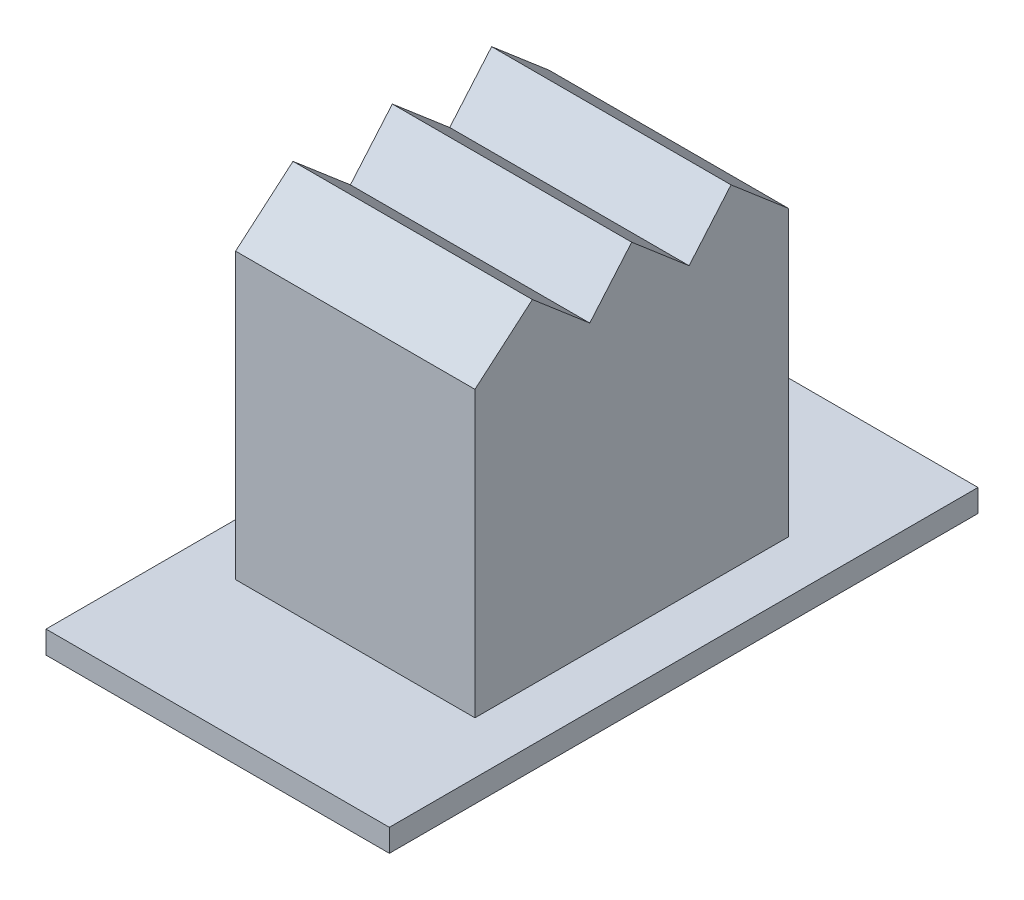
from build123d import *

# Parameters (mm, degrees)
SKICA1_W                 = 7
SKICA1_H                 = 12
SKICA1_W_2               = 2.46
SKICA1_H_2               = 2.37
P_IDAT_VYSUNUT_M1_DEPTH  = 0.46
SKICA2_W                 = 4.88
SKICA2_H                 = 6.39
SKICA2_W_2               = 2.46
SKICA2_H_2               = 2.37
P_IDAT_VYSUNUT_M2_DEPTH  = 4
SKICA3_W                 = 4.88
SKICA3_H                 = 6.39
P_IDAT_VYSUNUT_M3_DEPTH  = 2.8
ODEBRAT_VYSUNUT_M1_DEPTH = 10


with BuildPart() as part:
    # Skica1 → Přidat vysunutím1 (new body)
    with BuildSketch(Plane(origin=(0, 0, 0), x_dir=(1, 0, 0), z_dir=(0, 1, 0))):
        with Locations((3.5, 6)):
            Rectangle(SKICA1_W, SKICA1_H)
        with Locations((3.5, 6)):
            Rectangle(SKICA1_W_2, SKICA1_H_2, mode=Mode.SUBTRACT)
    extrude(amount=P_IDAT_VYSUNUT_M1_DEPTH)

    # Skica2 → Přidat vysunutím2 (add)
    with BuildSketch(Plane(origin=(0, 0.46, 0), x_dir=(1, 0, 0), z_dir=(0, 1, 0))):
        with Locations((3.5, 6)):
            Rectangle(SKICA2_W, SKICA2_H)
        with Locations((3.5, 6)):
            Rectangle(SKICA2_W_2, SKICA2_H_2, mode=Mode.SUBTRACT)
    extrude(amount=P_IDAT_VYSUNUT_M2_DEPTH)

    # Skica3 → Přidat vysunutím3 (add)
    with BuildSketch(Plane(origin=(0, 4.46, 0), x_dir=(1, 0, 0), z_dir=(0, 1, 0))):
        with Locations((3.5, 6)):
            Rectangle(SKICA3_W, SKICA3_H)
    extrude(amount=P_IDAT_VYSUNUT_M3_DEPTH)

    # Skica4 → Odebrat vysunutím1 (cut)
    with BuildSketch(Plane.ZY.offset(-1.06)):
        Polygon((-9.195, 7.26), (-9.195, 6.26), (-8.024764385, 7.26), align=None)
        Polygon((-6, 7.26), (-8.024764385, 7.26), (-7.170235615, 6.26), align=None)
        Polygon((-3.975235615, 7.26), (-6, 7.26), (-5.145471231, 6.26), align=None)
        Polygon((-2.805, 7.26), (-3.975235615, 7.26), (-2.805, 6.26), align=None)
    extrude(amount=-ODEBRAT_VYSUNUT_M1_DEPTH, mode=Mode.SUBTRACT)


solid = part.part
